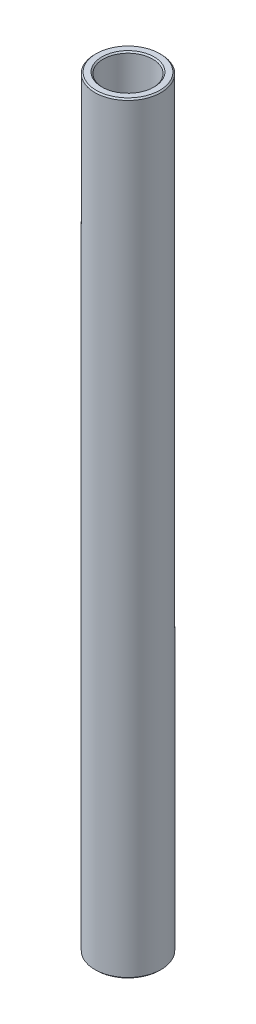
from build123d import *

# Parameters (mm, degrees)
SKETCH1_W     = 1.5875
SKETCH1_H     = 146.2341754
CHAMFER1_SIZE = 0.254


with BuildPart() as part:
    # Sketch1 → Revolve1 (revolve)
    with BuildSketch(Plane.XY):
        with Locations((5.55625, 0)):
            Rectangle(SKETCH1_W, SKETCH1_H)
    revolve(axis=Axis((0, 11.60859375, 0), (0, -1, 0)))

    # Chamfer1
    chamfer1_edges = [part.edges().sort_by_distance(p)[0] for p in [
        (-4.7625, -73.1170877, 0),
        (-6.35, -73.1170877, 0),
        (-6.35, 73.1170877, 0),
        (-4.7625, 73.1170877, 0),
    ]]
    chamfer(chamfer1_edges, length=CHAMFER1_SIZE)


solid = part.part
